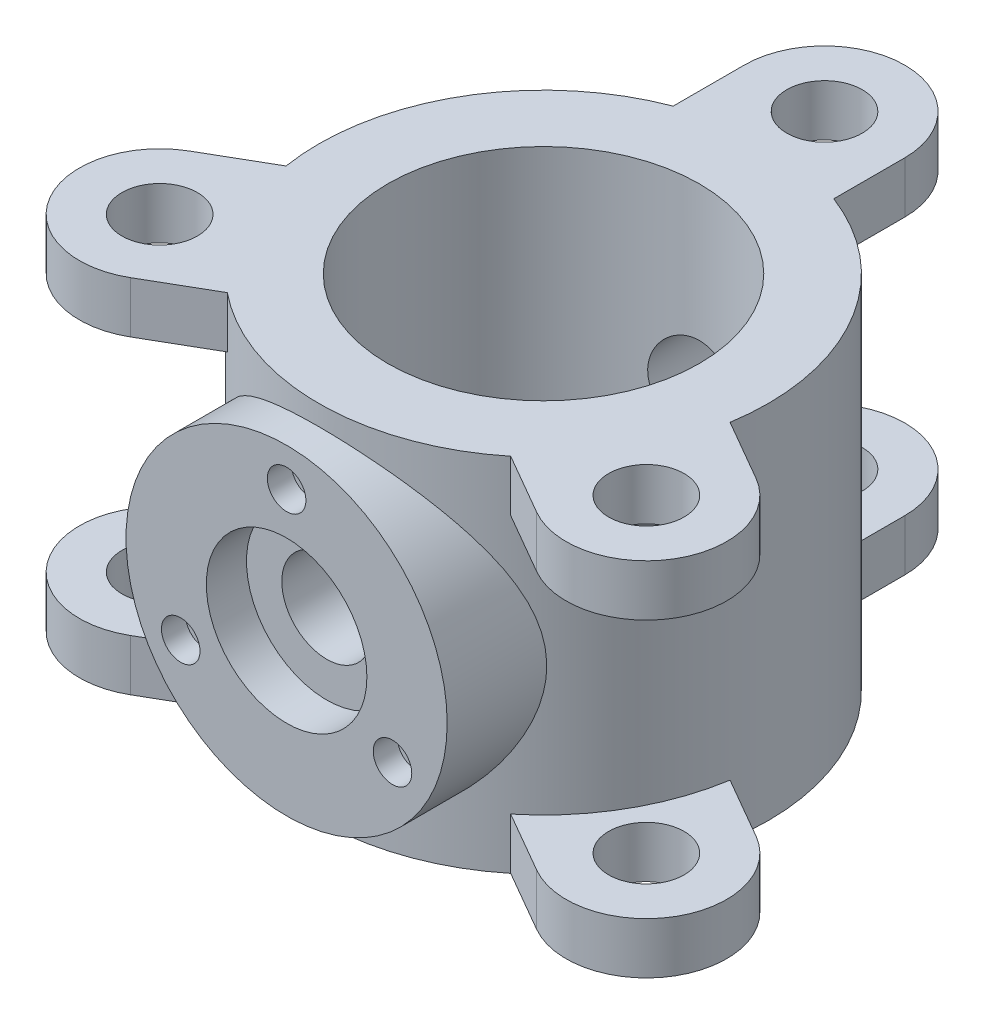
from build123d import *

# Parameters (mm, degrees)
SKETCH1_W           = 43
SKETCH1_H           = 225
SKETCH2_R           = 23.5
BOSS_EXTRUDE1_DEPTH = 32
CIRPATTERN1_COUNT   = 3
SKETCH3_R           = 23.5
BOSS_EXTRUDE2_DEPTH = 32
CIRPATTERN2_COUNT   = 3
BOSS_EXTRUDE4_START = 20
SKETCH5_R           = 100
BOSS_EXTRUDE4_DEPTH = 62
SKETCH6_R           = 50
CUT_EXTRUDE2_DEPTH  = 25
SKETCH4_R           = 28
CUT_EXTRUDE1_DEPTH  = 342
SKETCH7_R           = 12
CUT_EXTRUDE3_DEPTH  = 15
CIRPATTERN3_COUNT   = 3


with BuildPart() as part:
    # Sketch1 → Revolve1 (revolve)
    with BuildSketch(Plane.XY):
        with Locations((118.5, 112.5)):
            Rectangle(SKETCH1_W, SKETCH1_H)
    revolve(axis=Axis((0, 0, 0), (0, 1, 0)))

    # Sketch2 → Boss-Extrude1 (add)
    with BuildSketch(Plane(origin=(0, 225, 0), x_dir=(1, 0, 0), z_dir=(0, 1, 0))):
        with BuildLine():
            ThreePointArc((50, 175), (0, 225), (-50, 175))
            Line((-50, 175), (-50, 130.766968306))
            ThreePointArc((-50, 130.766968306), (0, 140), (50, 130.766968306))
            Line((50, 130.766968306), (50, 175))
        make_face()
        with Locations((0, 175)):
            Circle(SKETCH2_R, mode=Mode.SUBTRACT)
    boss_extrude1 = extrude(amount=-BOSS_EXTRUDE1_DEPTH)

    # CirPattern1: Boss-Extrude1 ×3 about axis
    cirpattern1_axis = Axis((0, 0, 0), (0, 1, 0))
    for i in range(1, CIRPATTERN1_COUNT):
        add(boss_extrude1.rotate(cirpattern1_axis, i * 360 / CIRPATTERN1_COUNT))

    # Sketch3 → Boss-Extrude2 (add)
    with BuildSketch(Plane(origin=(0, 0, 0), x_dir=(1, 0, 0), z_dir=(0, 1, 0))):
        with BuildLine():
            ThreePointArc((50, 175), (0, 225), (-50, 175))
            Line((-50, 175), (-50, 130.766968306))
            ThreePointArc((-50, 130.766968306), (0, 140), (50, 130.766968306))
            Line((50, 130.766968306), (50, 175))
        make_face()
        with Locations((0, 175)):
            Circle(SKETCH3_R, mode=Mode.SUBTRACT)
    boss_extrude2 = extrude(amount=BOSS_EXTRUDE2_DEPTH)

    # CirPattern2: Boss-Extrude2 ×3 about axis
    cirpattern2_axis = Axis((0, 0, 0), (0, 1, 0))
    for i in range(1, CIRPATTERN2_COUNT):
        add(boss_extrude2.rotate(cirpattern2_axis, i * 360 / CIRPATTERN2_COUNT))

    # Sketch5 → Boss-Extrude4 (add)
    with BuildSketch(Plane.XY.offset(140).offset(BOSS_EXTRUDE4_START)):
        with Locations((0, 112.5)):
            Circle(SKETCH5_R)
    extrude(amount=-BOSS_EXTRUDE4_DEPTH)

    # Sketch6 → Cut-Extrude2 (cut)
    with BuildSketch(Plane.XY.offset(160)):
        with Locations((0, 112.5)):
            Circle(SKETCH6_R)
    extrude(amount=-CUT_EXTRUDE2_DEPTH, mode=Mode.SUBTRACT)

    # Sketch4 → Cut-Extrude1 (cut)
    with BuildSketch(Plane.XY.offset(140)):
        with Locations((0, 112.5)):
            Circle(SKETCH4_R)
    extrude(amount=-CUT_EXTRUDE1_DEPTH, mode=Mode.SUBTRACT)

    # Sketch7 → Cut-Extrude3 (cut)
    with BuildSketch(Plane.XY.offset(160)):
        with Locations((0, 188.646045953)):
            Circle(SKETCH7_R)
    cut_extrude3 = extrude(amount=-CUT_EXTRUDE3_DEPTH, mode=Mode.SUBTRACT)

    # CirPattern3: Cut-Extrude3 ×3 about axis
    cirpattern3_axis = Axis((0, 112.5, 0), (0, 0, 1))
    for i in range(1, CIRPATTERN3_COUNT):
        add(cut_extrude3.rotate(cirpattern3_axis, i * 360 / CIRPATTERN3_COUNT), mode=Mode.SUBTRACT)


solid = part.part
